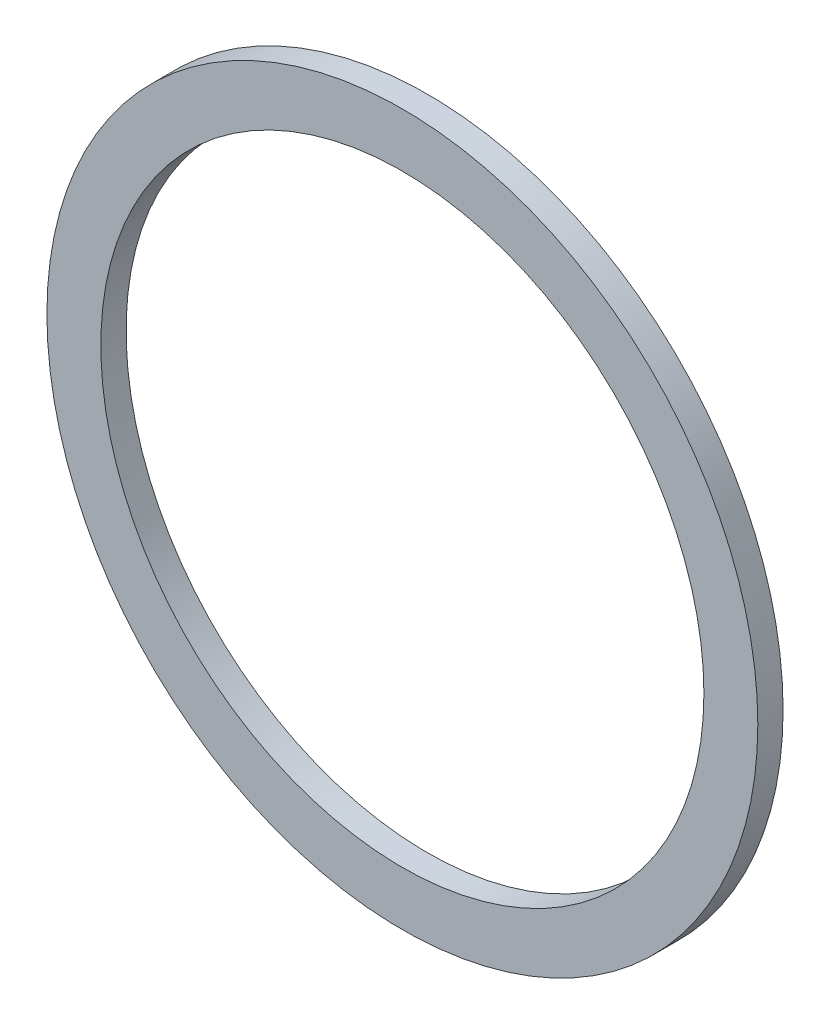
from build123d import *

# Parameters (mm, degrees)
SKETCH1_R           = 10.55
SKETCH1_R_2         = 8.95
BOSS_EXTRUDE1_DEPTH = 0.75


with BuildPart() as part:
    # Sketch1 → Boss-Extrude1 (new body)
    with BuildSketch(Plane.XY):
        Circle(SKETCH1_R)
        Circle(SKETCH1_R_2, mode=Mode.SUBTRACT)
    extrude(amount=BOSS_EXTRUDE1_DEPTH)


solid = part.part
